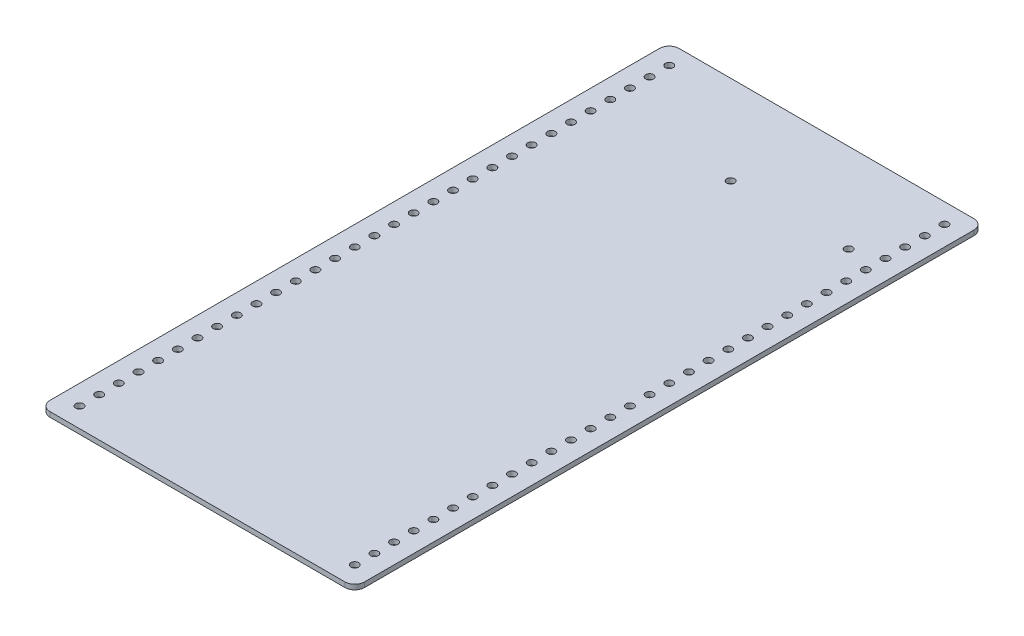
from build123d import *

# Parameters (mm, degrees)
BOSS_EXTRUDE1_DEPTH = 3.175
SKETCH3_R           = 2.5
CUT_EXTRUDE2_DEPTH  = 4.175
SKETCH7_R           = 2.5
CUT_EXTRUDE5_DEPTH  = 4.175


with BuildPart() as part:
    # Sketch1 → Boss-Extrude1 (new body)
    with BuildSketch(Plane(origin=(0, 0, 0), x_dir=(1, 0, 0), z_dir=(0, 1, 0))):
        with BuildLine():
            Line((-77.88977591, 288.008963585), (112.61022409, 288.008963585))
            ThreePointArc((112.61022409, 288.008963585), (117.10035215, 286.149091646), (118.96022409, 281.658963585))
            Line((118.96022409, 281.658963585), (118.96022409, -112.041036415))
            ThreePointArc((118.96022409, -112.041036415), (117.10035215, -116.531164475), (112.61022409, -118.391036415))
            Line((112.61022409, -118.391036415), (-77.88977591, -118.391036415))
            ThreePointArc((-77.88977591, -118.391036415), (-82.379903971, -116.531164475), (-84.23977591, -112.041036415))
            Line((-84.23977591, -112.041036415), (-84.23977591, 281.658963585))
            ThreePointArc((-84.23977591, 281.658963585), (-82.379903971, 286.149091646), (-77.88977591, 288.008963585))
        make_face()
    extrude(amount=BOSS_EXTRUDE1_DEPTH)

    # Sketch3 → Cut-Extrude2 (cut, through all)
    with BuildSketch(Plane(origin=(0, 3.175, 0), x_dir=(1, 0, 0), z_dir=(0, 1, 0))):
        with Locations((-71.53977591, 275.308963585)):
            Circle(SKETCH3_R)
        with Locations((106.26022409, 275.308963585)):
            Circle(SKETCH3_R)
        with Locations((-71.53977591, 262.608963585)):
            Circle(SKETCH3_R)
        with Locations((106.26022409, 262.608963585)):
            Circle(SKETCH3_R)
        with Locations((-71.53977591, 249.908963585)):
            Circle(SKETCH3_R)
        with Locations((106.26022409, 249.908963585)):
            Circle(SKETCH3_R)
        with Locations((-71.53977591, 237.208963585)):
            Circle(SKETCH3_R)
        with Locations((106.26022409, 237.208963585)):
            Circle(SKETCH3_R)
        with Locations((-71.53977591, 224.508963585)):
            Circle(SKETCH3_R)
        with Locations((106.26022409, 224.508963585)):
            Circle(SKETCH3_R)
        with Locations((-71.53977591, 211.808963585)):
            Circle(SKETCH3_R)
        with Locations((106.26022409, 211.808963585)):
            Circle(SKETCH3_R)
        with Locations((-71.53977591, 199.108963585)):
            Circle(SKETCH3_R)
        with Locations((106.26022409, 199.108963585)):
            Circle(SKETCH3_R)
        with Locations((-71.53977591, 186.408963585)):
            Circle(SKETCH3_R)
        with Locations((106.26022409, 186.408963585)):
            Circle(SKETCH3_R)
        with Locations((-71.53977591, 173.708963585)):
            Circle(SKETCH3_R)
        with Locations((106.26022409, 173.708963585)):
            Circle(SKETCH3_R)
        with Locations((-71.53977591, 161.008963585)):
            Circle(SKETCH3_R)
        with Locations((106.26022409, 161.008963585)):
            Circle(SKETCH3_R)
        with Locations((-71.53977591, 148.308963585)):
            Circle(SKETCH3_R)
        with Locations((106.26022409, 148.308963585)):
            Circle(SKETCH3_R)
        with Locations((-71.53977591, 135.608963585)):
            Circle(SKETCH3_R)
        with Locations((106.26022409, 135.608963585)):
            Circle(SKETCH3_R)
        with Locations((-71.53977591, 122.908963585)):
            Circle(SKETCH3_R)
        with Locations((106.26022409, 122.908963585)):
            Circle(SKETCH3_R)
        with Locations((-71.53977591, 110.208963585)):
            Circle(SKETCH3_R)
        with Locations((106.26022409, 110.208963585)):
            Circle(SKETCH3_R)
        with Locations((-71.53977591, 97.508963585)):
            Circle(SKETCH3_R)
        with Locations((106.26022409, 97.508963585)):
            Circle(SKETCH3_R)
        with Locations((-71.53977591, 84.808963585)):
            Circle(SKETCH3_R)
        with Locations((106.26022409, 84.808963585)):
            Circle(SKETCH3_R)
        with Locations((-71.53977591, 72.108963585)):
            Circle(SKETCH3_R)
        with Locations((106.26022409, 72.108963585)):
            Circle(SKETCH3_R)
        with Locations((-71.53977591, 59.408963585)):
            Circle(SKETCH3_R)
        with Locations((106.26022409, 59.408963585)):
            Circle(SKETCH3_R)
        with Locations((-71.53977591, 46.708963585)):
            Circle(SKETCH3_R)
        with Locations((106.26022409, 46.708963585)):
            Circle(SKETCH3_R)
        with Locations((-71.53977591, 34.008963585)):
            Circle(SKETCH3_R)
        with Locations((106.26022409, 34.008963585)):
            Circle(SKETCH3_R)
        with Locations((-71.53977591, 21.308963585)):
            Circle(SKETCH3_R)
        with Locations((106.26022409, 21.308963585)):
            Circle(SKETCH3_R)
        with Locations((-71.53977591, 8.608963585)):
            Circle(SKETCH3_R)
        with Locations((106.26022409, 8.608963585)):
            Circle(SKETCH3_R)
        with Locations((-71.53977591, -4.091036415)):
            Circle(SKETCH3_R)
        with Locations((106.26022409, -4.091036415)):
            Circle(SKETCH3_R)
        with Locations((-71.53977591, -16.791036415)):
            Circle(SKETCH3_R)
        with Locations((106.26022409, -16.791036415)):
            Circle(SKETCH3_R)
        with Locations((-71.53977591, -29.491036415)):
            Circle(SKETCH3_R)
        with Locations((106.26022409, -29.491036415)):
            Circle(SKETCH3_R)
        with Locations((-71.53977591, -42.191036415)):
            Circle(SKETCH3_R)
        with Locations((106.26022409, -42.191036415)):
            Circle(SKETCH3_R)
        with Locations((-71.53977591, -54.891036415)):
            Circle(SKETCH3_R)
        with Locations((106.26022409, -54.891036415)):
            Circle(SKETCH3_R)
        with Locations((-71.53977591, -67.591036415)):
            Circle(SKETCH3_R)
        with Locations((106.26022409, -67.591036415)):
            Circle(SKETCH3_R)
        with Locations((-71.53977591, -80.291036415)):
            Circle(SKETCH3_R)
        with Locations((106.26022409, -80.291036415)):
            Circle(SKETCH3_R)
        with Locations((-71.53977591, -92.991036415)):
            Circle(SKETCH3_R)
        with Locations((106.26022409, -92.991036415)):
            Circle(SKETCH3_R)
        with Locations((-71.53977591, -105.691036415)):
            Circle(SKETCH3_R)
        with Locations((106.26022409, -105.691036415)):
            Circle(SKETCH3_R)
    extrude(amount=-CUT_EXTRUDE2_DEPTH, mode=Mode.SUBTRACT)

    # Sketch7 → Cut-Extrude5 (cut, through all)
    with BuildSketch(Plane(origin=(0, 3.175, 0), x_dir=(1, 0, 0), z_dir=(0, 1, 0))):
        with Locations((89.075893655, 230.566598453)):
            Circle(SKETCH7_R)
        with Locations((12.875893655, 230.566598453)):
            Circle(SKETCH7_R)
    extrude(amount=-CUT_EXTRUDE5_DEPTH, mode=Mode.SUBTRACT)


solid = part.part
